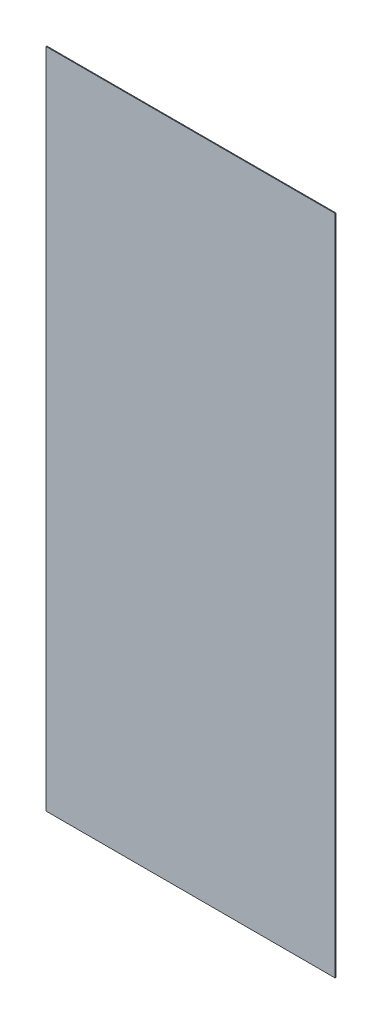
from build123d import *

# Parameters (mm, degrees)
SKETCH_1_W      = 358
SKETCH_1_H      = 820
EXTRUDE_1_DEPTH = 1


with BuildPart() as part:
    # 스케치1 → 보스-돌출1 (new body)
    with BuildSketch(Plane.XY):
        with Locations((179, 410)):
            Rectangle(SKETCH_1_W, SKETCH_1_H)
    extrude(amount=EXTRUDE_1_DEPTH)


solid = part.part
